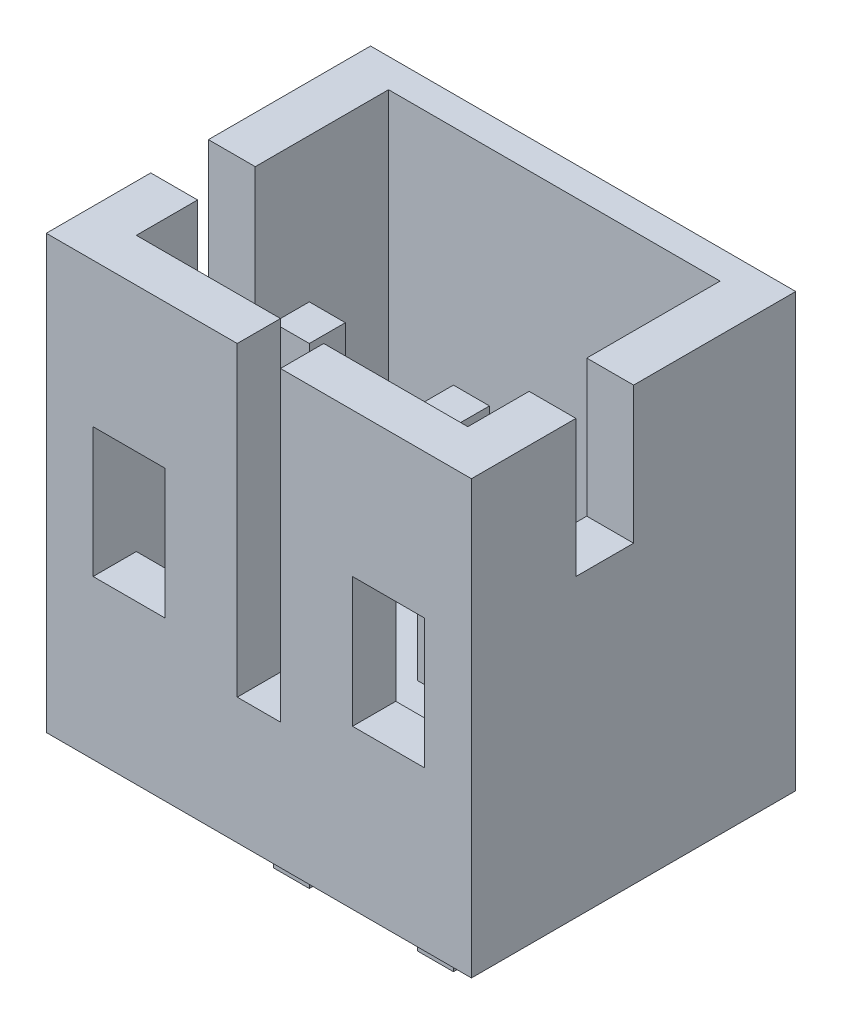
from build123d import *

# Parameters (mm, degrees)
SKETCH1_W            = 1.75
SKETCH1_H            = 4.1
BOSS_EXTRUDE1_DEPTH  = 1.6
BOSS_EXTRUDE2_DEPTH  = 2
SKETCH3_W            = 1
SKETCH3_H            = 0.6
BOSS_EXTRUDE3_DEPTH  = 1.8
SKETCH4_W            = 1
SKETCH4_H            = 0.6
BOSS_EXTRUDE4_DEPTH  = 2.25
BOSS_EXTRUDE5_DEPTH  = 1
SKETCH6_W            = 4.1
SKETCH6_H            = 4
BOSS_EXTRUDE6_DEPTH  = 0.65
SKETCH7_W            = 2
SKETCH7_H            = 0.6
BOSS_EXTRUDE7_DEPTH  = 2
SKETCH8_W            = 4.1
SKETCH8_H            = 6
BOSS_EXTRUDE8_DEPTH  = 0.65
SKETCH9_W            = 5.9
SKETCH9_H            = 6
BOSS_EXTRUDE9_DEPTH  = 0.4
SKETCH10_W           = 0.8
SKETCH10_H           = 1.9
CUT_EXTRUDE1_DEPTH   = 1.65
SKETCH11_W           = 0.8
SKETCH11_H           = 1.9
CUT_EXTRUDE2_DEPTH   = 6.9
SKETCH12_W           = 0.5
SKETCH12_H           = 0.5
BOSS_EXTRUDE10_DEPTH = 3.3
SKETCH13_W           = 0.5
SKETCH13_H           = 0.5
BOSS_EXTRUDE11_DEPTH = 3.3
SKETCH14_W           = 0.5
SKETCH14_H           = 0.5
BOSS_EXTRUDE12_DEPTH = 1.5
SKETCH15_W           = 0.5
SKETCH15_H           = 0.5
BOSS_EXTRUDE13_DEPTH = 1.5


with BuildPart() as part:
    # Sketch1 → Boss-Extrude1 (new body)
    with BuildSketch(Plane(origin=(4.6, 0, 0), x_dir=(0, -1, 0), z_dir=(-1, 0, 0))):
        with Locations((-0.875, 2.45)):
            Rectangle(SKETCH1_W, SKETCH1_H)
    extrude(amount=-BOSS_EXTRUDE1_DEPTH)

    # Sketch2 → Boss-Extrude2 (add)
    with BuildSketch(Plane(origin=(6.2, 0, 0), x_dir=(0, 0, -1), z_dir=(1, 0, 0))):
        Polygon((-3.9, 1.75), (-0.4, 1.75), (-0.4, 0), (-4.5, 0), (-4.5, 2.2), (-3.9, 2.2), align=None)
    extrude(amount=BOSS_EXTRUDE2_DEPTH)

    # Sketch3 → Boss-Extrude3 (add)
    with BuildSketch(Plane(origin=(0, 2.2, 0), x_dir=(-1, 0, 0), z_dir=(0, 1, 0))):
        with Locations((-6.7, 4.2)):
            Rectangle(SKETCH3_W, SKETCH3_H)
    extrude(amount=BOSS_EXTRUDE3_DEPTH)

    # Sketch4 → Boss-Extrude4 (add)
    with BuildSketch(Plane(origin=(0, 1.75, 0), x_dir=(-1, 0, 0), z_dir=(0, 1, 0))):
        with Locations((-5.1, 4.2)):
            Rectangle(SKETCH4_W, SKETCH4_H)
    extrude(amount=BOSS_EXTRUDE4_DEPTH)

    # Sketch5 → Boss-Extrude5 (add)
    with BuildSketch(Plane.ZY.offset(-4.6)):
        Polygon((0.4, 0), (0.4, 1.75), (3.9, 1.75), (3.9, 2.2), (4.5, 2.2), (4.5, 0), align=None)
    extrude(amount=BOSS_EXTRUDE5_DEPTH)

    # Sketch6 → Boss-Extrude6 (add)
    with BuildSketch(Plane.ZY.offset(-3.6)):
        with Locations((2.45, 2)):
            Rectangle(SKETCH6_W, SKETCH6_H)
    extrude(amount=BOSS_EXTRUDE6_DEPTH)

    # Sketch7 → Boss-Extrude7 (add)
    with BuildSketch(Plane(origin=(0, 4, 0), x_dir=(-1, 0, 0), z_dir=(0, 1, 0))):
        with Locations((-7.2, 4.2)):
            Rectangle(SKETCH7_W, SKETCH7_H)
        Polygon((-3.6, 0.4), (-3.6, 3.9), (-5.6, 3.9), (-5.6, 4.5), (-2.95, 4.5), (-2.95, 0.4), align=None)
    extrude(amount=BOSS_EXTRUDE7_DEPTH)

    # Sketch8 → Boss-Extrude8 (add)
    with BuildSketch(Plane(origin=(8.2, 0, 0), x_dir=(0, 0, -1), z_dir=(1, 0, 0))):
        with Locations((-2.45, 3)):
            Rectangle(SKETCH8_W, SKETCH8_H)
    extrude(amount=BOSS_EXTRUDE8_DEPTH)

    # Sketch9 → Boss-Extrude9 (add)
    with BuildSketch(Plane(origin=(0, 0, 0.4), x_dir=(-1, 0, 0), z_dir=(0, 0, -1))):
        with Locations((-5.9, 3)):
            Rectangle(SKETCH9_W, SKETCH9_H)
    extrude(amount=BOSS_EXTRUDE9_DEPTH)

    # Sketch10 → Cut-Extrude1 (cut, through all)
    with BuildSketch(Plane(origin=(3.6, 0, 0), x_dir=(0, 0, -1), z_dir=(1, 0, 0))):
        with Locations((-2.65, 5.05)):
            Rectangle(SKETCH10_W, SKETCH10_H)
    extrude(amount=-CUT_EXTRUDE1_DEPTH, mode=Mode.SUBTRACT)

    # Sketch11 → Cut-Extrude2 (cut, through all)
    with BuildSketch(Plane(origin=(8.85, 0, 0), x_dir=(0, 0, -1), z_dir=(1, 0, 0))):
        with Locations((-2.65, 5.05)):
            Rectangle(SKETCH11_W, SKETCH11_H)
    extrude(amount=-CUT_EXTRUDE2_DEPTH, mode=Mode.SUBTRACT)

    # Sketch12 → Boss-Extrude10 (add)
    with BuildSketch(Plane(origin=(0, 1.75, 0), x_dir=(-1, 0, 0), z_dir=(0, 1, 0))):
        with Locations((-4.9, 2.8)):
            Rectangle(SKETCH12_W, SKETCH12_H)
    extrude(amount=BOSS_EXTRUDE10_DEPTH)

    # Sketch13 → Boss-Extrude11 (add)
    with BuildSketch(Plane(origin=(0, 1.75, 0), x_dir=(-1, 0, 0), z_dir=(0, 1, 0))):
        with Locations((-6.9, 2.8)):
            Rectangle(SKETCH13_W, SKETCH13_H)
    extrude(amount=BOSS_EXTRUDE11_DEPTH)

    # Sketch14 → Boss-Extrude12 (add)
    with BuildSketch(Plane.XZ):
        with Locations((4.9, 2.8)):
            Rectangle(SKETCH14_W, SKETCH14_H)
    extrude(amount=BOSS_EXTRUDE12_DEPTH)

    # Sketch15 → Boss-Extrude13 (add)
    with BuildSketch(Plane.XZ):
        with Locations((6.9, 2.8)):
            Rectangle(SKETCH15_W, SKETCH15_H)
    extrude(amount=BOSS_EXTRUDE13_DEPTH)


solid = part.part
